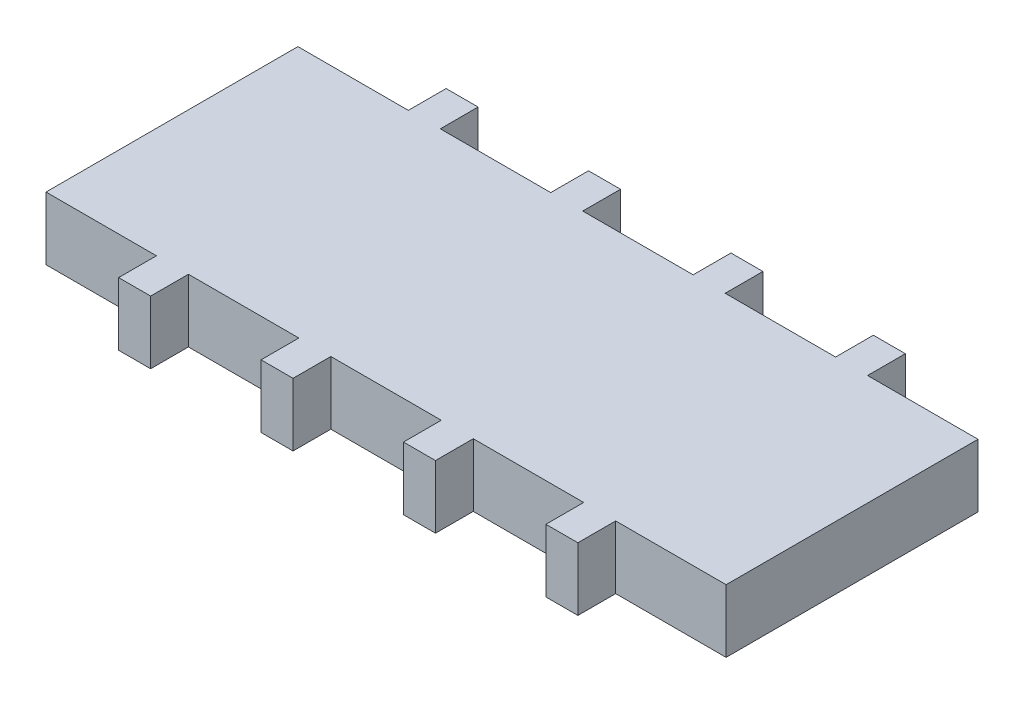
from build123d import *

# Parameters (mm, degrees)
SKETCH1_W           = 54
SKETCH1_H           = 20
SKETCH1_W_2         = 2.54
SKETCH1_H_2         = 3
BOSS_EXTRUDE1_DEPTH = 5


with BuildPart() as part:
    # Sketch1 → Boss-Extrude1 (new body)
    with BuildSketch(Plane(origin=(0, 0, 0), x_dir=(1, 0, 0), z_dir=(0, 1, 0))):
        Rectangle(SKETCH1_W, SKETCH1_H)
        with Locations((-16.962, -11.5)):
            Rectangle(SKETCH1_W_2, SKETCH1_H_2)
        with Locations((-5.654, -11.5)):
            Rectangle(SKETCH1_W_2, SKETCH1_H_2)
        with Locations((5.654, -11.5)):
            Rectangle(SKETCH1_W_2, SKETCH1_H_2)
        with Locations((16.962, -11.5)):
            Rectangle(SKETCH1_W_2, SKETCH1_H_2)
        with Locations((16.962, 11.5)):
            Rectangle(SKETCH1_W_2, SKETCH1_H_2)
        with Locations((5.654, 11.5)):
            Rectangle(SKETCH1_W_2, SKETCH1_H_2)
        with Locations((-5.654, 11.5)):
            Rectangle(SKETCH1_W_2, SKETCH1_H_2)
        with Locations((-16.962, 11.5)):
            Rectangle(SKETCH1_W_2, SKETCH1_H_2)
    extrude(amount=BOSS_EXTRUDE1_DEPTH)


solid = part.part
